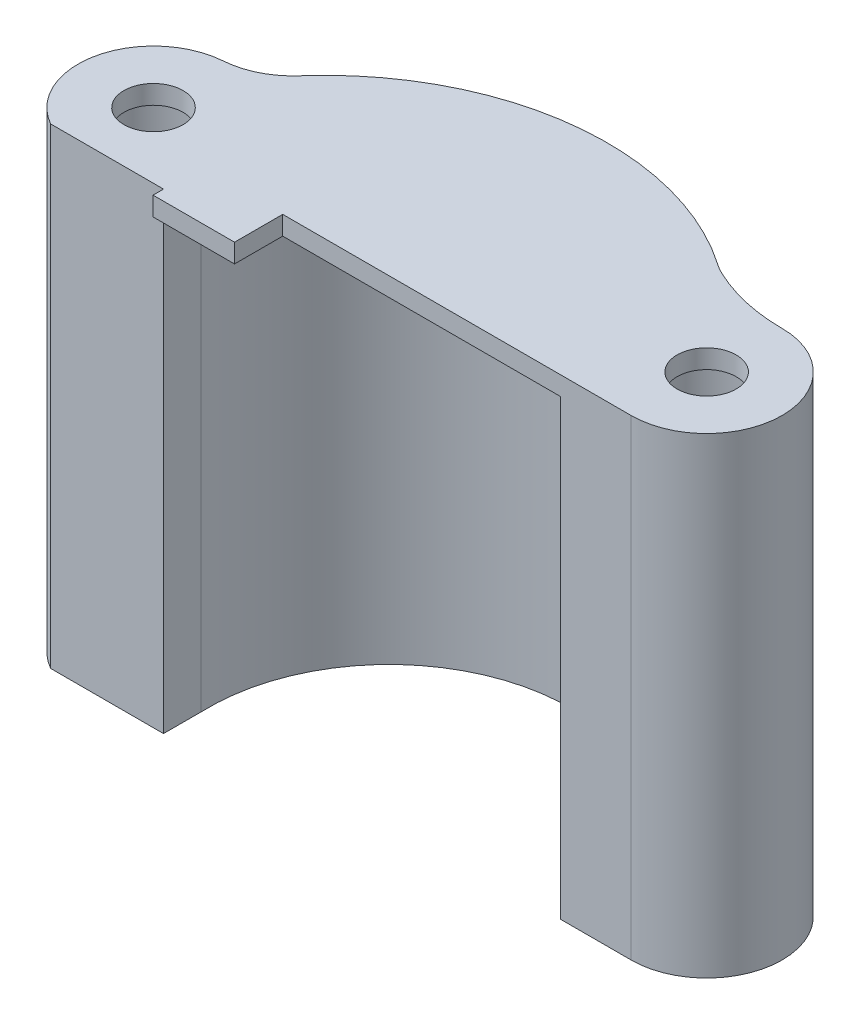
from build123d import *

# Parameters (mm, degrees)
SKETCH2_R           = 4.7625
BOSS_EXTRUDE1_DEPTH = 38.1
SKETCH3_R           = 2.4892
BOSS_EXTRUDE2_DEPTH = 1.5875
SKETCH4_W           = 6.858
SKETCH4_H           = 4.056568305
SKETCH4_W_2         = 20.112893425
SKETCH4_H_2         = 3.175
BOSS_EXTRUDE3_DEPTH = 1.5875
FILLET2_R           = 6.35


with BuildPart() as part:
    # Sketch2 → Boss-Extrude1 (new body)
    with BuildSketch(Plane(origin=(0, 0, 0), x_dir=(1, 0, 0), z_dir=(0, 1, 0))):
        with BuildLine():
            Line((-13.637822674, -18.9154966), (-13.637822674, -15.7404966))
            ThreePointArc((-13.637822674, -15.7404966), (0, 0), (16.609085938, -12.5654966))
            Line((16.609085938, -12.5654966), (16.609085938, -15.7404966))
            Line((16.609085938, -15.7404966), (22.545691393, -15.7404966))
            ThreePointArc((22.545691393, -15.7404966), (28.895691393, -9.3904966), (22.545691393, -3.0404966))
            ThreePointArc((22.545691393, -3.0404966), (18.914562129, -2.601594541), (15.492581173, -1.310168551))
            ThreePointArc((15.492581173, -1.310168551), (-2.207478742, 2.815047226), (-17.640279185, -6.783817119))
            ThreePointArc((-17.640279185, -6.783817119), (-18.810770101, -6.984553123), (-19.996688426, -7.047335697))
            ThreePointArc((-19.996688426, -7.047335697), (-26.135207048, -11.772192893), (-23.138726022, -18.9154966))
            Line((-23.138726022, -18.9154966), (-13.637822674, -18.9154966))
        make_face()
        with Locations((-19.996688426, -13.397335697)):
            Circle(SKETCH2_R, mode=Mode.SUBTRACT)
        with Locations((22.545691393, -9.3904966)):
            Circle(SKETCH2_R, mode=Mode.SUBTRACT)
    extrude(amount=BOSS_EXTRUDE1_DEPTH)

    # Sketch3 → Boss-Extrude2 (add)
    with BuildSketch(Plane(origin=(0, 38.1, 0), x_dir=(-1, 0, 0), z_dir=(0, 1, 0))):
        with BuildLine():
            Line((13.637822674, 15.7404966), (3.503807487, 15.7404966))
            Line((3.503807487, 15.7404966), (3.503807487, 12.5654966))
            Line((3.503807487, 12.5654966), (-16.609085938, 12.5654966))
            Line((-16.609085938, 12.5654966), (-16.609085938, 15.7404966))
            Line((-16.609085938, 15.7404966), (-22.545691393, 15.7404966))
            ThreePointArc((-22.545691393, 15.7404966), (-28.895691393, 9.3904966), (-22.545691393, 3.0404966))
            ThreePointArc((-22.545691393, 3.0404966), (-18.914562129, 2.601594541), (-15.492581173, 1.310168551))
            ThreePointArc((-15.492581173, 1.310168551), (2.207478742, -2.815047226), (17.640279185, 6.783817119))
            ThreePointArc((17.640279185, 6.783817119), (18.810770101, 6.984553123), (19.996688426, 7.047335697))
            ThreePointArc((19.996688426, 7.047335697), (26.135207048, 11.772192893), (23.138726022, 18.9154966))
            Line((23.138726022, 18.9154966), (13.637822674, 18.9154966))
            Line((13.637822674, 18.9154966), (13.637822674, 15.7404966))
        make_face()
        with Locations((-22.545691393, 9.3904966)):
            Circle(SKETCH3_R, mode=Mode.SUBTRACT)
        with Locations((19.996688426, 13.397335697)):
            Circle(SKETCH3_R, mode=Mode.SUBTRACT)
    extrude(amount=BOSS_EXTRUDE2_DEPTH)

    # Sketch4 → Boss-Extrude3 (add)
    with BuildSketch(Plane(origin=(0, 39.6875, 0), x_dir=(-1, 0, 0), z_dir=(0, 1, 0))):
        with Locations((10.208822674, 17.768780752)):
            Rectangle(SKETCH4_W, SKETCH4_H)
        with Locations((-6.552639226, 14.1529966)):
            Rectangle(SKETCH4_W_2, SKETCH4_H_2)
    extrude(amount=-BOSS_EXTRUDE3_DEPTH)

    # Fillet2
    fillet2_edges = [part.edges().sort_by_distance(p)[0] for p in [
        (15.492581173, 19.84375, 1.310168551),
        (-17.640279185, 19.84375, 6.783817119),
    ]]
    fillet(fillet2_edges, radius=FILLET2_R)


solid = part.part
